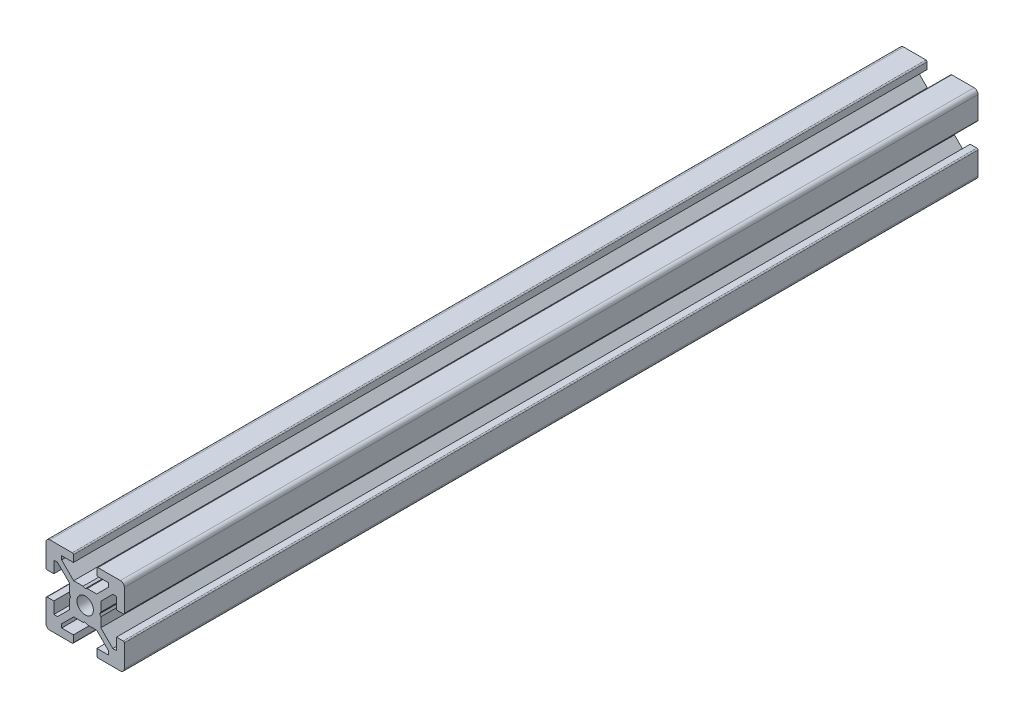
from build123d import *

# Parameters (mm, degrees)
BOSS_EXTRUDE1_DEPTH = 218
SKETCH2_W           = 407.5
SKETCH2_H           = 2.1


with BuildPart() as part:
    # Sketch1 → Boss-Extrude1 (new body)
    with BuildSketch(Plane.XY):
        with BuildLine():
            Line((-10, 9), (-10, 3.29999995))
            ThreePointArc((-10, 3.29999995), (-9.912132049, 3.087867916), (-9.7, 3))
            Line((-9.7, 3), (-8, 3))
            Line((-8, 3), (-8, 6))
            Line((-8, 6), (-7.060677, 6))
            Line((-7.060677, 6), (-4, 2.93932965))
            Line((-4, 2.93932965), (-4, 0.519615242))
            Line((-4, 0.519615242), (-3.699996283, -6.437e-06))
            Line((-3.699996283, -6.437e-06), (-4, -0.519628117))
            Line((-4, -0.519628117), (-4, -2.93933725))
            Line((-4, -2.93933725), (-7.0606695, -6))
            Line((-7.0606695, -6), (-8, -6))
            Line((-8, -6), (-8, -3))
            Line((-8, -3), (-9.7, -3))
            ThreePointArc((-9.7, -3), (-9.912132049, -3.087867916), (-10, -3.29999995))
            Line((-10, -3.29999995), (-10, -9))
            ThreePointArc((-10, -9), (-9.707106781, -9.707106781), (-9, -10))
            Line((-9, -10), (-3.29999995, -10))
            ThreePointArc((-3.29999995, -10), (-3.087867916, -9.912132049), (-3, -9.7))
            Line((-3, -9.7), (-3, -8))
            Line((-3, -8), (-6, -8))
            Line((-6, -8), (-6, -7.0606515))
            Line((-6, -7.0606515), (-2.9393489, -4))
            Line((-2.9393489, -4), (-0.519615242, -4))
            Line((-0.519615242, -4), (6.437e-06, -3.699996283))
            Line((6.437e-06, -3.699996283), (0.519628117, -4))
            Line((0.519628117, -4), (2.9393227, -4))
            Line((2.9393227, -4), (6, -7.060677))
            Line((6, -7.060677), (6, -8))
            Line((6, -8), (3, -8))
            Line((3, -8), (3, -9.7))
            ThreePointArc((3, -9.7), (3.087867916, -9.912132049), (3.29999995, -10))
            Line((3.29999995, -10), (9, -10))
            ThreePointArc((9, -10), (9.707106781, -9.707106781), (10, -9))
            Line((10, -9), (10, -3.29999995))
            ThreePointArc((10, -3.29999995), (9.912132049, -3.087867916), (9.7, -3))
            Line((9.7, -3), (8, -3))
            Line((8, -3), (8, -6))
            Line((8, -6), (7.0606435, -6))
            Line((7.0606435, -6), (4, -2.9393482))
            Line((4, -2.9393482), (4, -0.519615242))
            Line((4, -0.519615242), (3.699996283, 6.437e-06))
            Line((3.699996283, 6.437e-06), (4, 0.519628117))
            Line((4, 0.519628117), (4, 2.9393401))
            Line((4, 2.9393401), (7.060651, 6))
            Line((7.060651, 6), (8, 6))
            Line((8, 6), (8, 3))
            Line((8, 3), (9.7, 3))
            ThreePointArc((9.7, 3), (9.912132049, 3.087867916), (10, 3.29999995))
            Line((10, 3.29999995), (10, 9))
            ThreePointArc((10, 9), (9.707106781, 9.707106781), (9, 10))
            Line((9, 10), (3.29999995, 10))
            ThreePointArc((3.29999995, 10), (3.087867916, 9.912132049), (3, 9.7))
            Line((3, 9.7), (3, 8))
            Line((3, 8), (6, 8))
            Line((6, 8), (6, 7.060669))
            Line((6, 7.060669), (2.9393308, 4))
            Line((2.9393308, 4), (0.519615242, 4))
            Line((0.519615242, 4), (-6.437e-06, 3.699996283))
            Line((-6.437e-06, 3.699996283), (-0.519628117, 4))
            Line((-0.519628117, 4), (-2.93935655, 4))
            Line((-2.93935655, 4), (-6, 7.0606435))
            Line((-6, 7.0606435), (-6, 8))
            Line((-6, 8), (-3, 8))
            Line((-3, 8), (-3, 9.7))
            ThreePointArc((-3, 9.7), (-3.087867966, 9.912132034), (-3.3, 10))
            Line((-3.3, 10), (-9, 10))
            ThreePointArc((-9, 10), (-9.707106781, 9.707106781), (-10, 9))
        make_face()
    extrude(amount=-BOSS_EXTRUDE1_DEPTH)

    # Sketch2 → Cut-Revolve1 (revolve, cut)
    with BuildSketch(Plane(origin=(0, 0, 0), x_dir=(0, 0, -1), z_dir=(1, 0, 0))):
        with Locations((203.75, 1.05)):
            Rectangle(SKETCH2_W, SKETCH2_H)
    revolve(axis=Axis((0, 0, -407.5), (0, 0, 1)), mode=Mode.SUBTRACT)


solid = part.part
